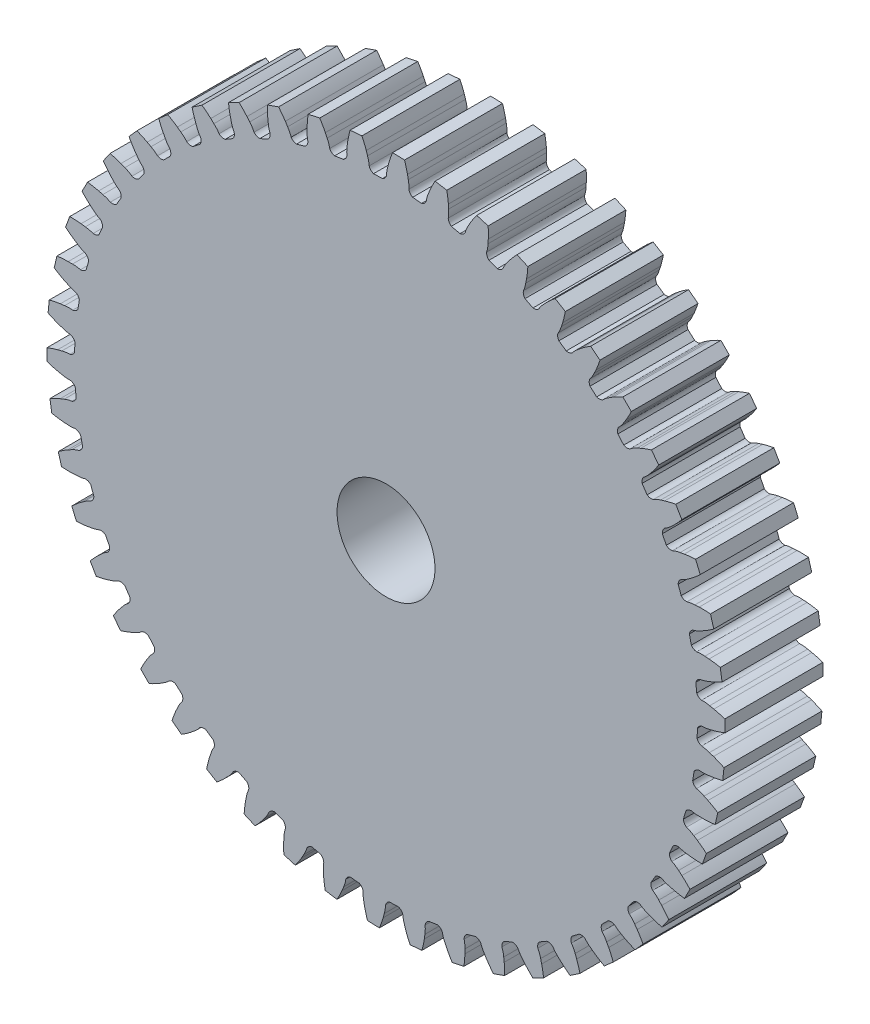
from build123d import *

# Parameters (mm, degrees)
SKETCH1_R           = 4.7625
BOSS_EXTRUDE1_DEPTH = 9.525


with BuildPart() as part:
    # Sketch1 → Boss-Extrude1 (new body)
    with BuildSketch(Plane.XY.offset(1.5875)):
        with BuildLine():
            Line((6.085438436, 30.919392842), (6.062246116, 31.336269955))
            ThreePointArc((6.062246116, 31.336269955), (6.001052011, 31.883634451), (5.910596918, 32.426930398))
            Line((5.910596918, 32.426930398), (4.768209334, 32.614492662))
            ThreePointArc((4.768209334, 32.614492662), (4.508784057, 32.128641722), (4.275782706, 31.62957962))
            Line((4.275782706, 31.62957962), (4.120511883, 31.242003688))
            ThreePointArc((4.120511883, 31.242003688), (3.986075895, 30.873495612), (3.905799746, 30.489533403))
            ThreePointArc((3.905799746, 30.489533403), (3.727534066, 30.231876604), (3.451724443, 30.083233639))
            Line((3.451724443, 30.083233639), (2.587721108, 30.169836618))
            ThreePointArc((2.587721108, 30.169836618), (2.346900416, 30.370263844), (2.223319664, 30.658176117))
            ThreePointArc((2.223319664, 30.658176117), (2.220847526, 31.050432572), (2.162225747, 31.438291727))
            Line((2.162225747, 31.438291727), (2.086968012, 31.848975337))
            ThreePointArc((2.086968012, 31.848975337), (1.95765348, 32.384354046), (1.799818614, 32.912028913))
            Line((1.799818614, 32.912028913), (0.642931656, 32.954932589))
            ThreePointArc((0.642931656, 32.954932589), (0.446445294, 32.44039812), (0.277830295, 31.91606846))
            Line((0.277830295, 31.91606846), (0.172358481, 31.512087724))
            ThreePointArc((0.172358481, 31.512087724), (0.08516887, 31.129636146), (0.053648947, 30.738640325))
            ThreePointArc((0.053648947, 30.738640325), (-0.090918094, 30.460672611), (-0.345922972, 30.278633629))
            Line((-0.345922972, 30.278633629), (-1.213966616, 30.256265696))
            ThreePointArc((-1.213966616, 30.256265696), (-1.478008558, 30.424929657), (-1.636699814, 30.695082881))
            ThreePointArc((-1.636699814, 30.695082881), (-1.688315229, 31.083936434), (-1.795086399, 31.461389947))
            Line((-1.795086399, 31.461389947), (-1.921223502, 31.859402127))
            ThreePointArc((-1.921223502, 31.859402127), (-2.116619096, 32.374351806), (-2.339344585, 32.878083845))
            Line((-2.339344585, 32.878083845), (-3.492487041, 32.775654376))
            ThreePointArc((-3.492487041, 32.775654376), (-3.62293578, 32.240550893), (-3.724505268, 31.699222666))
            Line((-3.724505268, 31.699222666), (-3.778512742, 31.285208424))
            ThreePointArc((-3.778512742, 31.285208424), (-3.817080944, 30.894844835), (-3.799347552, 30.502981639))
            ThreePointArc((-3.799347552, 30.502981639), (-3.907936047, 30.209086729), (-4.138114602, 29.996522592))
            Line((-4.138114602, 29.996522592), (-4.996509748, 29.865535709))
            ThreePointArc((-4.996509748, 29.865535709), (-5.27960884, 29.999776475), (-5.470907945, 30.247910171))
            ThreePointArc((-5.470907945, 30.247910171), (-5.57085263, 30.627228372), (-5.724089348, 30.988323575))
            Line((-5.724089348, 30.988323575), (-5.89911614, 31.367388156))
            ThreePointArc((-5.89911614, 31.367388156), (-6.157511289, 31.853787742), (-6.441614886, 32.325632798))
            Line((-6.441614886, 32.325632798), (-7.57282653, 32.07948314))
            ThreePointArc((-7.57282653, 32.07948314), (-7.635180392, 31.532249546), (-7.668102557, 30.982459821))
            Line((-7.668102557, 30.982459821), (-7.669793667, 30.564942038))
            ThreePointArc((-7.669793667, 30.564942038), (-7.659132216, 30.172822706), (-7.592425175, 29.786272052))
            ThreePointArc((-7.592425175, 29.786272052), (-7.663322618, 29.481084845), (-7.865044795, 29.241347818))
            Line((-7.865044795, 29.241347818), (-8.700255525, 29.003808645))
            ThreePointArc((-8.700255525, 29.003808645), (-8.997947125, 29.101509159), (-9.218837178, 29.323710111))
            ThreePointArc((-9.218837178, 29.323710111), (-9.365534946, 29.687510883), (-9.562820575, 30.026553089))
            Line((-9.562820575, 30.026553089), (-9.783976429, 30.380691916))
            ThreePointArc((-9.783976429, 30.380691916), (-10.101296088, 30.830870596), (-10.44229731, 31.26338739))
            Line((-10.44229731, 31.26338739), (-11.533737667, 30.877400197))
            ThreePointArc((-11.533737667, 30.877400197), (-11.527013311, 30.326666697), (-11.490768998, 29.777085989))
            Line((-11.490768998, 29.777085989), (-11.440118251, 29.362647673))
            ThreePointArc((-11.440118251, 29.362647673), (-11.380395286, 28.974956553), (-11.265766607, 28.599814575))
            ThreePointArc((-11.265766607, 28.599814575), (-11.297854903, 28.288148054), (-11.467939424, 28.025018932))
            Line((-11.467939424, 28.025018932), (-12.266792404, 27.684673899))
            ThreePointArc((-12.266792404, 27.684673899), (-12.574381738, 27.744293364), (-12.821379171, 27.937057331))
            ThreePointArc((-12.821379171, 27.937057331), (-13.012516511, 28.27960332), (-13.25073974, 28.591245632))
            Line((-13.25073974, 28.591245632), (-13.514537215, 28.914874117))
            ThreePointArc((-13.514537215, 28.914874117), (-13.885777064, 29.321732305), (-14.278298117, 29.708099788))
            Line((-14.278298117, 29.708099788), (-15.312755079, 29.188361936))
            ThreePointArc((-15.312755079, 29.188361936), (-15.23705852, 28.642813917), (-15.132219229, 28.102109438))
            Line((-15.132219229, 28.102109438), (-15.030024806, 27.697287318))
            ThreePointArc((-15.030024806, 27.697287318), (-14.922182192, 27.32013853), (-14.761439638, 26.962321442))
            ThreePointArc((-14.761439638, 26.962321442), (-14.754212735, 26.649090775), (-14.889977265, 26.366719262))
            Line((-14.889977265, 26.366719262), (-15.639875071, 25.928934516))
            ThreePointArc((-15.639875071, 25.928934516), (-15.952511272, 25.949532697), (-16.221720788, 26.109819677))
            ThreePointArc((-16.221720788, 26.109819677), (-16.454283349, 26.425708727), (-16.729687256, 26.705036359))
            Line((-16.729687256, 26.705036359), (-17.031965222, 26.993050323))
            ThreePointArc((-17.031965222, 26.993050323), (-17.451270586, 27.350171622), (-17.88912118, 27.684296549))
            Line((-17.88912118, 27.684296549), (-18.850280985, 27.039006064))
            ThreePointArc((-18.850280985, 27.039006064), (-18.706806018, 26.507247149), (-18.535025176, 25.983946133))
            Line((-18.535025176, 25.983946133), (-18.382899573, 25.59512483))
            ThreePointArc((-18.382899573, 25.59512483), (-18.228638052, 25.234466237), (-18.024316629, 24.899617027))
            ThreePointArc((-18.024316629, 24.899617027), (-17.977888499, 24.589762048), (-18.07719195, 24.292601311))
            Line((-18.07719195, 24.292601311), (-18.766306679, 23.764281408))
            ThreePointArc((-18.766306679, 23.764281408), (-19.079059286, 23.745533461), (-19.36623529, 23.87081563))
            ThreePointArc((-19.36623529, 23.87081563), (-19.636555422, 24.155065983), (-19.944796722, 24.39767377))
            Line((-19.944796722, 24.39767377), (-20.280789146, 24.645531267))
            ThreePointArc((-20.280789146, 24.645531267), (-20.741547329, 24.947283661), (-21.217822298, 25.223896683))
            Line((-21.217822298, 25.223896683), (-22.090527723, 24.463229262))
            ThreePointArc((-22.090527723, 24.463229262), (-21.881537035, 23.953645606), (-21.645523728, 23.456000825))
            Line((-21.645523728, 23.456000825), (-21.445865244, 23.089311554))
            ThreePointArc((-21.445865244, 23.089311554), (-21.247617614, 22.750830957), (-21.002939592, 22.444230398))
            ThreePointArc((-21.002939592, 22.444230398), (-20.918042436, 22.142637706), (-20.979318734, 21.835374148))
            Line((-20.979318734, 21.835374148), (-21.596782974, 21.224851026))
            ThreePointArc((-21.596782974, 21.224851026), (-21.904719693, 21.167052617), (-22.205333247, 21.255354202))
            ThreePointArc((-22.205333247, 21.255354202), (-22.509147841, 21.50348306), (-22.845365384, 21.705544934))
            Line((-22.845365384, 21.705544934), (-23.209773217, 21.90933683))
            ThreePointArc((-23.209773217, 21.90933683), (-23.704717787, 22.150961503), (-24.21190599, 22.365700267))
            Line((-24.21190599, 22.365700267), (-24.982392281, 21.501652308))
            ThreePointArc((-24.982392281, 21.501652308), (-24.711181779, 21.022280351), (-24.414658078, 20.558139957))
            Line((-24.414658078, 20.558139957), (-24.170615976, 20.2193654))
            ThreePointArc((-24.170615976, 20.2193654), (-23.931508721, 19.908400839), (-23.650332818, 19.634884205))
            ThreePointArc((-23.650332818, 19.634884205), (-23.528305514, 19.346310096), (-23.550588294, 19.033789446))
            Line((-23.550588294, 19.033789446), (-24.086664767, 18.350692018))
            ThreePointArc((-24.086664767, 18.350692018), (-24.384929251, 18.254754661), (-24.694239501, 18.304683093))
            ThreePointArc((-24.694239501, 18.304683093), (-25.026757217, 18.512777315), (-25.385648653, 18.671106638))
            Line((-25.385648653, 18.671106638), (-25.772725689, 18.827619065))
            ThreePointArc((-25.772725689, 18.827619065), (-26.294051076, 19.005305452), (-26.824153852, 19.154783399))
            Line((-26.824153852, 19.154783399), (-27.480270644, 18.200980636))
            ThreePointArc((-27.480270644, 18.200980636), (-27.151117481, 17.759380359), (-26.798759741, 17.336064126))
            Line((-26.798759741, 17.336064126), (-26.51418142, 17.030548191))
            ThreePointArc((-26.51418142, 17.030548191), (-26.237985403, 16.752003765), (-25.924745932, 16.515884576))
            ThreePointArc((-25.924745932, 16.515884576), (-25.767512924, 16.244880038), (-25.750450774, 15.932030933))
            Line((-25.750450774, 15.932030933), (-26.196686033, 15.1871315))
            ThreePointArc((-26.196686033, 15.1871315), (-26.480574474, 15.054568186), (-26.793703412, 15.065336063))
            ThreePointArc((-26.793703412, 15.065336063), (-27.149680248, 15.23011388), (-27.525585643, 15.342213705))
            Line((-27.525585643, 15.342213705), (-27.929226296, 15.448979136))
            ThreePointArc((-27.929226296, 15.448979136), (-28.468710885, 15.559925016), (-29.013368197, 15.64178479))
            Line((-29.013368197, 15.64178479), (-29.544768503, 14.613269187))
            ThreePointArc((-29.544768503, 14.613269187), (-29.16286362, 14.21640489), (-28.760228734, 13.840588766))
            Line((-28.760228734, 13.840588766), (-28.439603329, 13.573149218))
            ThreePointArc((-28.439603329, 13.573149218), (-28.130674327, 13.331417738), (-27.790311262, 13.136419735))
            ThreePointArc((-27.790311262, 13.136419735), (-27.600352208, 12.88725867), (-27.544214208, 12.579014929))
            Line((-27.544214208, 12.579014929), (-27.893569751, 11.784061661))
            ThreePointArc((-27.893569751, 11.784061661), (-28.158605058, 11.616962992), (-28.470614454, 11.588400499))
            ThreePointArc((-28.470614454, 11.588400499), (-28.844436444, 11.707263265), (-29.231427546, 11.771365712))
            Line((-29.231427546, 11.771365712), (-29.645266329, 11.826698552))
            ThreePointArc((-29.645266329, 11.826698552), (-30.194402127, 11.869154242), (-30.745024403, 11.882104865))
            Line((-30.745024403, 11.882104865), (-31.143327378, 10.795098128))
            ThreePointArc((-31.143327378, 10.795098128), (-30.714693643, 10.449228599), (-30.268131403, 10.126839429))
            Line((-30.268131403, 10.126839429), (-29.916515236, 9.901693916))
            ThreePointArc((-29.916515236, 9.901693916), (-29.579725242, 9.700587631), (-29.21760631, 9.54978605))
            ThreePointArc((-29.21760631, 9.54978605), (-28.997916978, 9.326397876), (-28.903588459, 9.027620686))
            Line((-28.903588459, 9.027620686), (-29.150555456, 8.195149524))
            ThreePointArc((-29.150555456, 8.195149524), (-29.392557863, 7.996150745), (-29.698527141, 7.928708328))
            ThreePointArc((-29.698527141, 7.928708328), (-30.084298888, 7.999781508), (-30.476272617, 8.014875641))
            Line((-30.476272617, 8.014875641), (-30.893782738, 8.017904628))
            ThreePointArc((-30.893782738, 8.017904628), (-31.443909545, 7.991200577), (-31.991813144, 7.935037811))
            Line((-31.991813144, 7.935037811), (-32.25073682, 6.806681784))
            ThreePointArc((-32.25073682, 6.806681784), (-31.782134044, 6.517261591), (-31.298687004, 6.253383646))
            Line((-31.298687004, 6.253383646), (-30.921625717, 6.074081718))
            ThreePointArc((-30.921625717, 6.074081718), (-30.562286113, 5.916772196), (-30.184122148, 5.812545266))
            ThreePointArc((-30.184122148, 5.812545266), (-29.938167169, 5.618452949), (-29.807135746, 5.333854205))
            Line((-29.807135746, 5.333854205), (-29.947819312, 4.476994858))
            ThreePointArc((-29.947819312, 4.476994858), (-30.162972298, 4.2492343), (-30.458076142, 4.143975568))
            ThreePointArc((-30.458076142, 4.143975568), (-30.849713795, 4.166138294), (-31.240488491, 4.13198607))
            Line((-31.240488491, 4.13198607), (-31.655086395, 4.082663752))
            ThreePointArc((-31.655086395, 4.082663752), (-32.197528383, 3.987221099), (-32.734072537, 3.862830663))
            Line((-32.734072537, 3.862830663), (-32.849533851, 2.710919691))
            ThreePointArc((-32.849533851, 2.710919691), (-32.348352179, 2.482513164), (-31.835644587, 2.281307956))
            Line((-31.835644587, 2.281307956), (-31.439083789, 2.150679158))
            ThreePointArc((-31.439083789, 2.150679158), (-31.062861573, 2.039647262), (-30.674616446, 1.983638706))
            ThreePointArc((-30.674616446, 1.983638706), (-30.406274678, 1.821903197), (-30.240606797, 1.555971191))
            Line((-30.240606797, 1.555971191), (-30.272787429, 0.68823538))
            ThreePointArc((-30.272787429, 0.68823538), (-30.457697902, 0.435304962), (-30.737282347, 0.293889908))
            ThreePointArc((-30.737282347, 0.293889908), (-31.128609546, 0.266792661), (-31.512022458, 0.183932681))
            Line((-31.512022458, 0.183932681), (-31.917169539, 0.083035566))
            ThreePointArc((-31.917169539, 0.083035566), (-32.443372074, -0.079640502), (-32.960095162, -0.270296896))
            Line((-32.960095162, -0.270296896), (-32.930274282, -1.42759468))
            ThreePointArc((-32.930274282, -1.42759468), (-32.404417649, -1.591385434), (-31.87053521, -1.726744778))
            Line((-31.87053521, -1.726744778), (-31.460728941, -1.80664165))
            ThreePointArc((-31.460728941, -1.80664165), (-31.073557364, -1.869644879), (-30.681353933, -1.876551774))
            ThreePointArc((-30.681353933, -1.876551774), (-30.394857286, -2.003379808), (-30.197165627, -2.24645117))
            Line((-30.197165627, -2.24645117), (-30.120336016, -3.11137848))
            ThreePointArc((-30.120336016, -3.11137848), (-30.272087828, -3.385489893), (-30.531743659, -3.560831069))
            ThreePointArc((-30.531743659, -3.560831069), (-30.916588941, -3.63676095), (-31.286593419, -3.767021934))
            Line((-31.286593419, -3.767021934), (-31.675900348, -3.9179011))
            ThreePointArc((-31.675900348, -3.9179011), (-32.1775649, -4.145245083), (-32.66631789, -4.399160671))
            Line((-32.66631789, -4.399160671), (-32.491683956, -5.543595523))
            ThreePointArc((-32.491683956, -5.543595523), (-31.949445434, -5.640187426), (-31.402807794, -5.707566209))
            Line((-31.402807794, -5.707566209), (-30.986219394, -5.735470936))
            ThreePointArc((-30.986219394, -5.735470936), (-30.594204378, -5.7494519), (-30.204227921, -5.707148207))
            ThreePointArc((-30.204227921, -5.707148207), (-29.904094651, -5.797068631), (-29.677497001, -6.013446004))
            Line((-29.677497001, -6.013446004), (-29.492869909, -6.861922732))
            ThreePointArc((-29.492869909, -6.861922732), (-29.609069842, -7.15289224), (-29.844702133, -7.359394304))
            ThreePointArc((-29.844702133, -7.359394304), (-30.216996256, -7.482959358), (-30.567757107, -7.658567052))
            Line((-30.567757107, -7.658567052), (-30.935083595, -7.857050144))
            ThreePointArc((-30.935083595, -7.857050144), (-31.404298616, -8.145476692), (-31.857373581, -8.458647072))
            Line((-31.857373581, -8.458647072), (-31.540680308, -9.57217011))
            ThreePointArc((-31.540680308, -9.57217011), (-30.990611324, -9.60003985), (-30.439839284, -9.598375468))
            Line((-30.439839284, -9.598375468), (-30.023038138, -9.573848376))
            ThreePointArc((-30.023038138, -9.573848376), (-29.632362002, -9.538586587), (-29.250762687, -9.447739461))
            ThreePointArc((-29.250762687, -9.447739461), (-28.941726009, -9.499334141), (-28.689795808, -9.685605052))
            Line((-28.689795808, -9.685605052), (-28.40028195, -10.504251243))
            ThreePointArc((-28.40028195, -10.504251243), (-28.479097464, -10.807490083), (-28.686990153, -11.041896373))
            ThreePointArc((-28.686990153, -11.041896373), (-29.040861818, -11.211147906), (-29.366847334, -11.429332874))
            Line((-29.366847334, -11.429332874), (-29.706401449, -11.672288879))
            ThreePointArc((-29.706401449, -11.672288879), (-30.135767138, -12.017249334), (-30.546018815, -12.384735621))
            Line((-30.546018815, -12.384735621), (-30.092261924, -13.449786068))
            ThreePointArc((-30.092261924, -13.449786068), (-29.543037394, -13.408494122), (-28.996816959, -13.337812823))
            Line((-28.996816959, -13.337812823), (-28.586376398, -13.261240036))
            ThreePointArc((-28.586376398, -13.261240036), (-28.203200333, -13.177291593), (-27.835996206, -13.039333748))
            ThreePointArc((-27.835996206, -13.039333748), (-27.522929847, -13.051789022), (-27.249640254, -13.205015905))
            Line((-27.249640254, -13.205015905), (-26.859805671, -13.980921564))
            ThreePointArc((-26.859805671, -13.980921564), (-26.899993796, -14.291647478), (-27.07686829, -14.550261268))
            ThreePointArc((-27.07686829, -14.550261268), (-27.406736731, -14.762530083), (-27.702805928, -15.019851416))
            Line((-27.702805928, -15.019851416), (-28.00923164, -15.303448859))
            ThreePointArc((-28.00923164, -15.303448859), (-28.391976643, -15.699502988), (-28.752935118, -16.115509706))
            Line((-28.752935118, -16.115509706), (-28.169269978, -17.115291233))
            ThreePointArc((-28.169269978, -17.115291233), (-27.6295515, -17.0054888), (-27.096496891, -16.866905271))
            Line((-27.096496891, -16.866905271), (-26.698890177, -16.739493865))
            ThreePointArc((-26.698890177, -16.739493865), (-26.329257101, -16.608182685), (-25.982239192, -16.425289799))
            ThreePointArc((-25.982239192, -16.425289799), (-25.670080395, -16.39840924), (-25.379741352, -16.516175615))
            Line((-25.379741352, -16.516175615), (-24.89573371, -17.237104081))
            ThreePointArc((-24.89573371, -17.237104081), (-24.896660657, -17.550416736), (-25.03972754, -17.829159531))
            ThreePointArc((-25.03972754, -17.829159531), (-25.340390532, -18.081098021), (-25.601874221, -18.373497609))
            Line((-25.601874221, -18.373497609), (-25.870340459, -18.693264551))
            ThreePointArc((-25.870340459, -18.693264551), (-26.200428659, -19.134166343), (-26.506401401, -19.592132817))
            Line((-26.506401401, -19.592132817), (-25.802031546, -20.510878331))
            ThreePointArc((-25.802031546, -20.510878331), (-25.280330803, -20.334297061), (-24.768848611, -20.129996847))
            Line((-24.768848611, -20.129996847), (-24.3903466, -19.953756287))
            ThreePointArc((-24.3903466, -19.953756287), (-24.040085845, -19.777153227), (-23.718726831, -19.552209629))
            ThreePointArc((-23.718726831, -19.552209629), (-23.412398527, -19.48641716), (-23.109588853, -19.566865781))
            Line((-23.109588853, -19.566865781), (-22.539042496, -20.221447404))
            ThreePointArc((-22.539042496, -20.221447404), (-22.500693645, -20.532405672), (-22.607696667, -20.826881532))
            ThreePointArc((-22.607696667, -20.826881532), (-22.874412576, -21.114516477), (-23.097187001, -21.437383002))
            Line((-23.097187001, -21.437383002), (-23.323457383, -21.788276077))
            ThreePointArc((-23.323457383, -21.788276077), (-23.595683092, -22.267072248), (-23.841844728, -22.759776073))
            Line((-23.841844728, -22.759776073), (-23.027880867, -23.582995438))
            ThreePointArc((-23.027880867, -23.582995438), (-22.532425392, -23.342420123), (-22.050581996, -23.07562516))
            Line((-22.050581996, -23.07562516), (-21.697152753, -22.853336525))
            ThreePointArc((-21.697152753, -22.853336525), (-21.371788142, -22.63422672), (-21.08115605, -22.370779906))
            ThreePointArc((-21.08115605, -22.370779906), (-20.785489219, -22.267113114), (-20.474984405, -22.308975257))
            Line((-20.474984405, -22.308975257), (-19.826895336, -22.886886495))
            ThreePointArc((-19.826895336, -22.886886495), (-19.749875472, -23.19058638), (-19.819127133, -23.496151244))
            ThreePointArc((-19.819127133, -23.496151244), (-20.047689689, -23.814946469), (-20.228241565, -24.163188133))
            Line((-20.228241565, -24.163188133), (-20.408750501, -24.53967271))
            ThreePointArc((-20.408750501, -24.53967271), (-20.618820555, -25.048812359), (-20.801288971, -25.5684833))
            Line((-20.801288971, -25.5684833), (-19.89056557, -26.283195764))
            ThreePointArc((-19.89056557, -26.283195764), (-19.429168992, -25.98242042), (-18.98456335, -25.657338224))
            Line((-18.98456335, -25.657338224), (-18.661781956, -25.392505186))
            ThreePointArc((-18.661781956, -25.392505186), (-18.366444682, -25.134344127), (-18.111122951, -24.836548809))
            ThreePointArc((-18.111122951, -24.836548809), (-17.830780436, -24.69664258), (-17.517477326, -24.699258055))
            Line((-17.517477326, -24.699258055), (-16.802066556, -25.191385053))
            ThreePointArc((-16.802066556, -25.191385053), (-16.687590328, -25.483037025), (-16.717998486, -25.794871954))
            ThreePointArc((-16.717998486, -25.794871954), (-16.904803122, -26.139799867), (-17.040285039, -26.507924692))
            Line((-17.040285039, -26.507924692), (-17.172184356, -26.904065367))
            ThreePointArc((-17.172184356, -26.904065367), (-17.316785827, -27.435519057), (-17.432683385, -27.973961594))
            Line((-17.432683385, -27.973961594), (-16.439564788, -28.568892965))
            ThreePointArc((-16.439564788, -28.568892965), (-16.019503605, -28.212661), (-15.619147415, -27.834418311))
            Line((-15.619147415, -27.834418311), (-15.332103182, -27.531218623))
            ThreePointArc((-15.332103182, -27.531218623), (-15.071450891, -27.238077666), (-14.855466099, -26.910630255))
            ThreePointArc((-14.855466099, -26.910630255), (-14.594869067, -26.736690995), (-14.28370864, -26.700018556))
            Line((-14.28370864, -26.700018556), (-13.512259585, -27.098601105))
            ThreePointArc((-13.512259585, -27.098601105), (-13.362132351, -27.373605637), (-13.353217452, -27.686792807))
            ThreePointArc((-13.353217452, -27.686792807), (-13.495318146, -28.05241369), (-13.583593473, -28.434616128))
            Line((-13.583593473, -28.434616128), (-13.664803323, -28.844163938))
            ThreePointArc((-13.664803323, -28.844163938), (-13.741655759, -29.389550327), (-13.789154686, -29.938272899))
            Line((-13.789154686, -29.938272899), (-12.729301879, -30.404042756))
            ThreePointArc((-12.729301879, -30.404042756), (-12.357200709, -29.99797216), (-12.007407826, -29.572534092))
            Line((-12.007407826, -29.572534092), (-11.7606287, -29.235749664))
            ThreePointArc((-11.7606287, -29.235749664), (-11.538772034, -28.912251817), (-11.365530389, -28.560316354))
            ThreePointArc((-11.365530389, -28.560316354), (-11.128788613, -28.355087187), (-10.824678055, -28.279705178))
            Line((-10.824678055, -28.279705178), (-10.009356524, -28.578456088))
            ThreePointArc((-10.009356524, -28.578456088), (-9.825945881, -28.832476196), (-9.777848518, -29.142076459))
            ThreePointArc((-9.777848518, -29.142076459), (-9.873004259, -29.522624251), (-9.912680841, -29.91287674))
            Line((-9.912680841, -29.91287674), (-9.941920181, -30.329372968))
            ThreePointArc((-9.941920181, -30.329372968), (-9.949811573, -30.880090987), (-9.928162782, -31.430439912))
            Line((-9.928162782, -31.430439912), (-8.818291242, -31.759702212))
            ThreePointArc((-8.818291242, -31.759702212), (-8.500018341, -31.310196961), (-8.206305209, -30.844272926))
            Line((-8.206305209, -30.844272926), (-8.003680824, -30.479214118))
            ThreePointArc((-8.003680824, -30.479214118), (-7.824118595, -30.130461136), (-7.696352222, -29.759587854))
            ThreePointArc((-7.696352222, -29.759587854), (-7.487199262, -29.526305369), (-7.194934578, -29.41340261))
            Line((-7.194934578, -29.41340261), (-6.348599059, -29.607611173))
            ThreePointArc((-6.348599059, -29.607611173), (-6.134797502, -29.836640808), (-6.048276199, -30.137771582))
            ThreePointArc((-6.048276199, -30.137771582), (-6.094986323, -30.527244818), (-6.085438437, -30.919392845))
            Line((-6.085438437, -30.919392845), (-6.062246117, -31.336269957))
            ThreePointArc((-6.062246117, -31.336269957), (-6.001052012, -31.883634453), (-5.910596919, -32.4269304))
            Line((-5.910596919, -32.4269304), (-4.768209335, -32.614492664))
            ThreePointArc((-4.768209335, -32.614492664), (-4.508784058, -32.128641724), (-4.275782707, -31.629579623))
            Line((-4.275782707, -31.629579623), (-4.120511884, -31.242003691))
            ThreePointArc((-4.120511884, -31.242003691), (-3.986075896, -30.873495614), (-3.905799747, -30.489533406))
            ThreePointArc((-3.905799747, -30.489533406), (-3.727534067, -30.231876606), (-3.451724445, -30.083233641))
            Line((-3.451724445, -30.083233641), (-2.587721109, -30.16983662))
            ThreePointArc((-2.587721109, -30.16983662), (-2.346900417, -30.370263847), (-2.223319666, -30.65817612))
            ThreePointArc((-2.223319666, -30.65817612), (-2.220847527, -31.050432574), (-2.162225749, -31.43829173))
            Line((-2.162225749, -31.43829173), (-2.086968013, -31.848975339))
            ThreePointArc((-2.086968013, -31.848975339), (-1.957653481, -32.384354048), (-1.799818615, -32.912028915))
            Line((-1.799818615, -32.912028915), (-0.642931657, -32.954932591))
            ThreePointArc((-0.642931657, -32.954932591), (-0.446445295, -32.440398122), (-0.277830296, -31.916068462))
            Line((-0.277830296, -31.916068462), (-0.172358482, -31.512087726))
            ThreePointArc((-0.172358482, -31.512087726), (-0.085168871, -31.129636149), (-0.053648948, -30.738640328))
            ThreePointArc((-0.053648948, -30.738640328), (0.090918093, -30.460672614), (0.345922971, -30.278633631))
            Line((0.345922971, -30.278633631), (1.213966615, -30.256265698))
            ThreePointArc((1.213966615, -30.256265698), (1.478008557, -30.42492966), (1.636699813, -30.695082884))
            ThreePointArc((1.636699813, -30.695082884), (1.688315228, -31.083936437), (1.795086398, -31.46138995))
            Line((1.795086398, -31.46138995), (1.921223501, -31.85940213))
            ThreePointArc((1.921223501, -31.85940213), (2.116619094, -32.374351809), (2.339344583, -32.878083847))
            Line((2.339344583, -32.878083847), (3.492487039, -32.775654378))
            ThreePointArc((3.492487039, -32.775654378), (3.622935779, -32.240550896), (3.724505266, -31.699222669))
            Line((3.724505266, -31.699222669), (3.778512741, -31.285208426))
            ThreePointArc((3.778512741, -31.285208426), (3.817080943, -30.894844837), (3.799347551, -30.502981641))
            ThreePointArc((3.799347551, -30.502981641), (3.907936046, -30.209086731), (4.138114601, -29.996522594))
            Line((4.138114601, -29.996522594), (4.996509747, -29.865535711))
            ThreePointArc((4.996509747, -29.865535711), (5.279608839, -29.999776477), (5.470907943, -30.247910174))
            ThreePointArc((5.470907943, -30.247910174), (5.570852629, -30.627228374), (5.724089346, -30.988323578))
            Line((5.724089346, -30.988323578), (5.899116138, -31.367388159))
            ThreePointArc((5.899116138, -31.367388159), (6.157511288, -31.853787745), (6.441614885, -32.3256328))
            Line((6.441614885, -32.3256328), (7.572826529, -32.079483142))
            ThreePointArc((7.572826529, -32.079483142), (7.635180391, -31.532249549), (7.668102555, -30.982459824))
            Line((7.668102555, -30.982459824), (7.669793666, -30.56494204))
            ThreePointArc((7.669793666, -30.56494204), (7.659132215, -30.172822708), (7.592425174, -29.786272054))
            ThreePointArc((7.592425174, -29.786272054), (7.663322617, -29.481084847), (7.865044794, -29.24134782))
            Line((7.865044794, -29.24134782), (8.700255524, -29.003808648))
            ThreePointArc((8.700255524, -29.003808648), (8.997947124, -29.101509161), (9.218837177, -29.323710114))
            ThreePointArc((9.218837177, -29.323710114), (9.365534945, -29.687510886), (9.562820574, -30.026553091))
            Line((9.562820574, -30.026553091), (9.783976428, -30.380691919))
            ThreePointArc((9.783976428, -30.380691919), (10.101296087, -30.830870599), (10.442297309, -31.263387392))
            Line((10.442297309, -31.263387392), (11.533737666, -30.877400199))
            ThreePointArc((11.533737666, -30.877400199), (11.52701331, -30.3266667), (11.490768997, -29.777085992))
            Line((11.490768997, -29.777085992), (11.44011825, -29.362647675))
            ThreePointArc((11.44011825, -29.362647675), (11.380395284, -28.974956555), (11.265766606, -28.599814578))
            ThreePointArc((11.265766606, -28.599814578), (11.297854902, -28.288148057), (11.467939423, -28.025018934))
            Line((11.467939423, -28.025018934), (12.266792403, -27.684673901))
            ThreePointArc((12.266792403, -27.684673901), (12.574381737, -27.744293366), (12.82137917, -27.937057334))
            ThreePointArc((12.82137917, -27.937057334), (13.01251651, -28.279603323), (13.250739739, -28.591245634))
            Line((13.250739739, -28.591245634), (13.514537214, -28.91487412))
            ThreePointArc((13.514537214, -28.91487412), (13.885777063, -29.321732307), (14.278298116, -29.708099791))
            Line((14.278298116, -29.708099791), (15.312755078, -29.188361939))
            ThreePointArc((15.312755078, -29.188361939), (15.237058519, -28.642813919), (15.132219228, -28.102109441))
            Line((15.132219228, -28.102109441), (15.030024805, -27.69728732))
            ThreePointArc((15.030024805, -27.69728732), (14.922182191, -27.320138533), (14.761439637, -26.962321445))
            ThreePointArc((14.761439637, -26.962321445), (14.754212734, -26.649090778), (14.889977264, -26.366719264))
            Line((14.889977264, -26.366719264), (15.63987507, -25.928934519))
            ThreePointArc((15.63987507, -25.928934519), (15.952511271, -25.9495327), (16.221720787, -26.109819679))
            ThreePointArc((16.221720787, -26.109819679), (16.454283348, -26.42570873), (16.729687255, -26.705036361))
            Line((16.729687255, -26.705036361), (17.031965221, -26.993050326))
            ThreePointArc((17.031965221, -26.993050326), (17.451270585, -27.350171624), (17.889121179, -27.684296552))
            Line((17.889121179, -27.684296552), (18.850280984, -27.039006067))
            ThreePointArc((18.850280984, -27.039006067), (18.706806016, -26.507247151), (18.535025174, -25.983946136))
            Line((18.535025174, -25.983946136), (18.382899571, -25.595124833))
            ThreePointArc((18.382899571, -25.595124833), (18.228638051, -25.234466239), (18.024316627, -24.89961703))
            ThreePointArc((18.024316627, -24.89961703), (17.977888498, -24.589762051), (18.077191949, -24.292601314))
            Line((18.077191949, -24.292601314), (18.766306677, -23.764281411))
            ThreePointArc((18.766306677, -23.764281411), (19.079059285, -23.745533463), (19.366235288, -23.870815633))
            ThreePointArc((19.366235288, -23.870815633), (19.636555421, -24.155065986), (19.944796721, -24.397673773))
            Line((19.944796721, -24.397673773), (20.280789145, -24.64553127))
            ThreePointArc((20.280789145, -24.64553127), (20.741547328, -24.947283663), (21.217822297, -25.223896686))
            Line((21.217822297, -25.223896686), (22.090527722, -24.463229265))
            ThreePointArc((22.090527722, -24.463229265), (21.881537034, -23.953645609), (21.645523727, -23.456000827))
            Line((21.645523727, -23.456000827), (21.445865243, -23.089311557))
            ThreePointArc((21.445865243, -23.089311557), (21.247617613, -22.750830959), (21.002939591, -22.444230401))
            ThreePointArc((21.002939591, -22.444230401), (20.918042435, -22.142637709), (20.979318733, -21.835374151))
            Line((20.979318733, -21.835374151), (21.596782973, -21.224851028))
            ThreePointArc((21.596782973, -21.224851028), (21.904719692, -21.167052619), (22.205333246, -21.255354204))
            ThreePointArc((22.205333246, -21.255354204), (22.50914784, -21.503483062), (22.845365383, -21.705544936))
            Line((22.845365383, -21.705544936), (23.209773216, -21.909336833))
            ThreePointArc((23.209773216, -21.909336833), (23.704717786, -22.150961506), (24.211905989, -22.36570027))
            Line((24.211905989, -22.36570027), (24.98239228, -21.501652311))
            ThreePointArc((24.98239228, -21.501652311), (24.711181778, -21.022280353), (24.414658077, -20.55813996))
            Line((24.414658077, -20.55813996), (24.170615975, -20.219365402))
            ThreePointArc((24.170615975, -20.219365402), (23.93150872, -19.908400842), (23.650332817, -19.634884208))
            ThreePointArc((23.650332817, -19.634884208), (23.528305513, -19.346310099), (23.550588293, -19.033789449))
            Line((23.550588293, -19.033789449), (24.086664766, -18.350692021))
            ThreePointArc((24.086664766, -18.350692021), (24.38492925, -18.254754664), (24.6942395, -18.304683095))
            ThreePointArc((24.6942395, -18.304683095), (25.026757216, -18.512777317), (25.385648652, -18.67110664))
            Line((25.385648652, -18.67110664), (25.772725688, -18.827619068))
            ThreePointArc((25.772725688, -18.827619068), (26.294051075, -19.005305454), (26.824153851, -19.154783402))
            Line((26.824153851, -19.154783402), (27.480270643, -18.200980639))
            ThreePointArc((27.480270643, -18.200980639), (27.151117479, -17.759380362), (26.79875974, -17.336064128))
            Line((26.79875974, -17.336064128), (26.514181419, -17.030548194))
            ThreePointArc((26.514181419, -17.030548194), (26.237985402, -16.752003767), (25.924745931, -16.515884579))
            ThreePointArc((25.924745931, -16.515884579), (25.767512923, -16.24488004), (25.750450773, -15.932030936))
            Line((25.750450773, -15.932030936), (26.196686032, -15.187131503))
            ThreePointArc((26.196686032, -15.187131503), (26.480574473, -15.054568189), (26.793703411, -15.065336066))
            ThreePointArc((26.793703411, -15.065336066), (27.149680247, -15.230113883), (27.525585642, -15.342213708))
            Line((27.525585642, -15.342213708), (27.929226295, -15.448979139))
            ThreePointArc((27.929226295, -15.448979139), (28.468710884, -15.559925019), (29.013368196, -15.641784793))
            Line((29.013368196, -15.641784793), (29.544768502, -14.61326919))
            ThreePointArc((29.544768502, -14.61326919), (29.162863619, -14.216404893), (28.760228733, -13.840588769))
            Line((28.760228733, -13.840588769), (28.439603328, -13.57314922))
            ThreePointArc((28.439603328, -13.57314922), (28.130674326, -13.33141774), (27.790311261, -13.136419738))
            ThreePointArc((27.790311261, -13.136419738), (27.600352207, -12.887258672), (27.544214207, -12.579014931))
            Line((27.544214207, -12.579014931), (27.89356975, -11.784061664))
            ThreePointArc((27.89356975, -11.784061664), (28.158605057, -11.616962994), (28.470614453, -11.588400501))
            ThreePointArc((28.470614453, -11.588400501), (28.844436443, -11.707263268), (29.231427545, -11.771365714))
            Line((29.231427545, -11.771365714), (29.645266328, -11.826698554))
            ThreePointArc((29.645266328, -11.826698554), (30.194402126, -11.869154244), (30.745024402, -11.882104868))
            Line((30.745024402, -11.882104868), (31.143327377, -10.795098131))
            ThreePointArc((31.143327377, -10.795098131), (30.714693642, -10.449228601), (30.268131402, -10.126839432))
            Line((30.268131402, -10.126839432), (29.916515235, -9.901693919))
            ThreePointArc((29.916515235, -9.901693919), (29.579725241, -9.700587634), (29.217606309, -9.549786053))
            ThreePointArc((29.217606309, -9.549786053), (28.997916977, -9.326397879), (28.903588458, -9.027620689))
            Line((28.903588458, -9.027620689), (29.150555455, -8.195149526))
            ThreePointArc((29.150555455, -8.195149526), (29.392557862, -7.996150747), (29.69852714, -7.928708331))
            ThreePointArc((29.69852714, -7.928708331), (30.084298886, -7.999781511), (30.476272615, -8.014875644))
            Line((30.476272615, -8.014875644), (30.893782736, -8.017904631))
            ThreePointArc((30.893782736, -8.017904631), (31.443909544, -7.99120058), (31.991813143, -7.935037814))
            Line((31.991813143, -7.935037814), (32.250736819, -6.806681787))
            ThreePointArc((32.250736819, -6.806681787), (31.782134043, -6.517261593), (31.298687003, -6.253383649))
            Line((31.298687003, -6.253383649), (30.921625716, -6.074081721))
            ThreePointArc((30.921625716, -6.074081721), (30.562286112, -5.916772198), (30.184122147, -5.812545269))
            ThreePointArc((30.184122147, -5.812545269), (29.938167168, -5.618452952), (29.807135745, -5.333854208))
            Line((29.807135745, -5.333854208), (29.947819311, -4.476994861))
            ThreePointArc((29.947819311, -4.476994861), (30.162972297, -4.249234303), (30.458076141, -4.143975571))
            ThreePointArc((30.458076141, -4.143975571), (30.849713794, -4.166138297), (31.24048849, -4.131986073))
            Line((31.24048849, -4.131986073), (31.655086394, -4.082663755))
            ThreePointArc((31.655086394, -4.082663755), (32.197528382, -3.987221102), (32.734072536, -3.862830666))
            Line((32.734072536, -3.862830666), (32.84953385, -2.710919694))
            ThreePointArc((32.84953385, -2.710919694), (32.348352178, -2.482513166), (31.835644586, -2.281307959))
            Line((31.835644586, -2.281307959), (31.439083788, -2.150679161))
            ThreePointArc((31.439083788, -2.150679161), (31.062861572, -2.039647265), (30.674616445, -1.983638709))
            ThreePointArc((30.674616445, -1.983638709), (30.406274677, -1.8219032), (30.240606796, -1.555971193))
            Line((30.240606796, -1.555971193), (30.272787428, -0.688235383))
            ThreePointArc((30.272787428, -0.688235383), (30.457697901, -0.435304965), (30.737282346, -0.293889911))
            ThreePointArc((30.737282346, -0.293889911), (31.128609545, -0.266792663), (31.512022457, -0.183932683))
            Line((31.512022457, -0.183932683), (31.917169538, -0.083035568))
            ThreePointArc((31.917169538, -0.083035568), (32.443372073, 0.079640499), (32.960095161, 0.270296893))
            Line((32.960095161, 0.270296893), (32.930274281, 1.427594677))
            ThreePointArc((32.930274281, 1.427594677), (32.404417647, 1.591385431), (31.870535209, 1.726744775))
            Line((31.870535209, 1.726744775), (31.46072894, 1.806641648))
            ThreePointArc((31.46072894, 1.806641648), (31.073557363, 1.869644876), (30.681353932, 1.876551772))
            ThreePointArc((30.681353932, 1.876551772), (30.394857285, 2.003379806), (30.197165626, 2.246451168))
            Line((30.197165626, 2.246451168), (30.120336015, 3.111378478))
            ThreePointArc((30.120336015, 3.111378478), (30.272087826, 3.38548989), (30.531743658, 3.560831067))
            ThreePointArc((30.531743658, 3.560831067), (30.91658894, 3.636760947), (31.286593417, 3.767021932))
            Line((31.286593417, 3.767021932), (31.675900347, 3.917901097))
            ThreePointArc((31.675900347, 3.917901097), (32.177564899, 4.145245081), (32.666317889, 4.399160668))
            Line((32.666317889, 4.399160668), (32.491683955, 5.54359552))
            ThreePointArc((32.491683955, 5.54359552), (31.949445433, 5.640187423), (31.402807793, 5.707566206))
            Line((31.402807793, 5.707566206), (30.986219393, 5.735470933))
            ThreePointArc((30.986219393, 5.735470933), (30.594204377, 5.749451898), (30.20422792, 5.707148204))
            ThreePointArc((30.20422792, 5.707148204), (29.90409465, 5.797068629), (29.677497, 6.013446001))
            Line((29.677497, 6.013446001), (29.492869908, 6.861922729))
            ThreePointArc((29.492869908, 6.861922729), (29.609069841, 7.152892237), (29.844702132, 7.359394301))
            ThreePointArc((29.844702132, 7.359394301), (30.216996255, 7.482959355), (30.567757106, 7.65856705))
            Line((30.567757106, 7.65856705), (30.935083594, 7.857050141))
            ThreePointArc((30.935083594, 7.857050141), (31.404298615, 8.14547669), (31.85737358, 8.458647069))
            Line((31.85737358, 8.458647069), (31.540680307, 9.572170107))
            ThreePointArc((31.540680307, 9.572170107), (30.990611323, 9.600039847), (30.439839283, 9.598375465))
            Line((30.439839283, 9.598375465), (30.023038137, 9.573848373))
            ThreePointArc((30.023038137, 9.573848373), (29.632362001, 9.538586584), (29.250762686, 9.447739458))
            ThreePointArc((29.250762686, 9.447739458), (28.941726008, 9.499334138), (28.689795807, 9.68560505))
            Line((28.689795807, 9.68560505), (28.400281949, 10.504251241))
            ThreePointArc((28.400281949, 10.504251241), (28.479097462, 10.80749008), (28.686990151, 11.041896371))
            ThreePointArc((28.686990151, 11.041896371), (29.040861817, 11.211147904), (29.366847333, 11.429332871))
            Line((29.366847333, 11.429332871), (29.706401448, 11.672288876))
            ThreePointArc((29.706401448, 11.672288876), (30.135767137, 12.017249331), (30.546018814, 12.384735618))
            Line((30.546018814, 12.384735618), (30.092261923, 13.449786066))
            ThreePointArc((30.092261923, 13.449786066), (29.543037393, 13.408494119), (28.996816957, 13.337812821))
            Line((28.996816957, 13.337812821), (28.586376397, 13.261240034))
            ThreePointArc((28.586376397, 13.261240034), (28.203200332, 13.17729159), (27.835996205, 13.039333745))
            ThreePointArc((27.835996205, 13.039333745), (27.522929846, 13.05178902), (27.249640253, 13.205015903))
            Line((27.249640253, 13.205015903), (26.85980567, 13.980921561))
            ThreePointArc((26.85980567, 13.980921561), (26.899993795, 14.291647476), (27.076868289, 14.550261266))
            ThreePointArc((27.076868289, 14.550261266), (27.40673673, 14.76253008), (27.702805927, 15.019851413))
            Line((27.702805927, 15.019851413), (28.009231639, 15.303448857))
            ThreePointArc((28.009231639, 15.303448857), (28.391976642, 15.699502985), (28.752935117, 16.115509704))
            Line((28.752935117, 16.115509704), (28.169269977, 17.115291231))
            ThreePointArc((28.169269977, 17.115291231), (27.629551499, 17.005488797), (27.09649689, 16.866905269))
            Line((27.09649689, 16.866905269), (26.698890176, 16.739493862))
            ThreePointArc((26.698890176, 16.739493862), (26.3292571, 16.608182683), (25.982239191, 16.425289797))
            ThreePointArc((25.982239191, 16.425289797), (25.670080394, 16.398409237), (25.379741351, 16.516175612))
            Line((25.379741351, 16.516175612), (24.895733709, 17.237104078))
            ThreePointArc((24.895733709, 17.237104078), (24.896660655, 17.550416733), (25.039727539, 17.829159529))
            ThreePointArc((25.039727539, 17.829159529), (25.340390531, 18.081098019), (25.60187422, 18.373497606))
            Line((25.60187422, 18.373497606), (25.870340458, 18.693264549))
            ThreePointArc((25.870340458, 18.693264549), (26.200428658, 19.134166341), (26.5064014, 19.592132815))
            Line((26.5064014, 19.592132815), (25.802031545, 20.510878329))
            ThreePointArc((25.802031545, 20.510878329), (25.280330802, 20.334297058), (24.76884861, 20.129996844))
            Line((24.76884861, 20.129996844), (24.390346599, 19.953756285))
            ThreePointArc((24.390346599, 19.953756285), (24.040085844, 19.777153225), (23.71872683, 19.552209627))
            ThreePointArc((23.71872683, 19.552209627), (23.412398526, 19.486417158), (23.109588852, 19.566865778))
            Line((23.109588852, 19.566865778), (22.539041445, 20.221447252))
            ThreePointArc((22.539041445, 20.221447252), (22.500692593, 20.53240552), (22.607695616, 20.82688138))
            ThreePointArc((22.607695616, 20.82688138), (22.874411525, 21.114516325), (23.097185951, 21.43738285))
            Line((23.097185951, 21.43738285), (23.323457382, 21.788276074))
            ThreePointArc((23.323457382, 21.788276074), (23.595683091, 22.267072246), (23.841844727, 22.75977607))
            Line((23.841844727, 22.75977607), (23.027880866, 23.582995435))
            ThreePointArc((23.027880866, 23.582995435), (22.532425391, 23.34242012), (22.050581995, 23.075625157))
            Line((22.050581995, 23.075625157), (21.697152752, 22.853336522))
            ThreePointArc((21.697152752, 22.853336522), (21.371788141, 22.634226717), (21.081156049, 22.370779903))
            ThreePointArc((21.081156049, 22.370779903), (20.785489218, 22.267113111), (20.474984404, 22.308975255))
            Line((20.474984404, 22.308975255), (19.826895335, 22.886886493))
            ThreePointArc((19.826895335, 22.886886493), (19.749875471, 23.190586377), (19.819127131, 23.496151242))
            ThreePointArc((19.819127131, 23.496151242), (20.047689688, 23.814946466), (20.228241564, 24.163188131))
            Line((20.228241564, 24.163188131), (20.4087505, 24.539672707))
            ThreePointArc((20.4087505, 24.539672707), (20.618820554, 25.048812356), (20.80128897, 25.568483298))
            Line((20.80128897, 25.568483298), (19.890565569, 26.283195762))
            ThreePointArc((19.890565569, 26.283195762), (19.429168991, 25.982420417), (18.984563349, 25.657338221))
            Line((18.984563349, 25.657338221), (18.661781955, 25.392505183))
            ThreePointArc((18.661781955, 25.392505183), (18.366444681, 25.134344125), (18.11112295, 24.836548807))
            ThreePointArc((18.11112295, 24.836548807), (17.830780435, 24.696642577), (17.517477325, 24.699258053))
            Line((17.517477325, 24.699258053), (16.802066555, 25.191385051))
            ThreePointArc((16.802066555, 25.191385051), (16.687590327, 25.483037022), (16.717998485, 25.794871951))
            ThreePointArc((16.717998485, 25.794871951), (16.904803121, 26.139799864), (17.040285038, 26.50792469))
            Line((17.040285038, 26.50792469), (17.172184355, 26.904065365))
            ThreePointArc((17.172184355, 26.904065365), (17.316785826, 27.435519054), (17.432683384, 27.973961592))
            Line((17.432683384, 27.973961592), (16.439564787, 28.568892963))
            ThreePointArc((16.439564787, 28.568892963), (16.019503604, 28.212660997), (15.619147414, 27.834418309))
            Line((15.619147414, 27.834418309), (15.332103181, 27.531218621))
            ThreePointArc((15.332103181, 27.531218621), (15.07145089, 27.238077664), (14.855466097, 26.910630252))
            ThreePointArc((14.855466097, 26.910630252), (14.594869066, 26.736690992), (14.283708639, 26.700018553))
            Line((14.283708639, 26.700018553), (13.512259584, 27.098601103))
            ThreePointArc((13.512259584, 27.098601103), (13.36213235, 27.373605635), (13.353217451, 27.686792805))
            ThreePointArc((13.353217451, 27.686792805), (13.495318145, 28.052413687), (13.583593472, 28.434616125))
            Line((13.583593472, 28.434616125), (13.664803322, 28.844163935))
            ThreePointArc((13.664803322, 28.844163935), (13.741655758, 29.389550324), (13.789154685, 29.938272897))
            Line((13.789154685, 29.938272897), (12.729301878, 30.404042754))
            ThreePointArc((12.729301878, 30.404042754), (12.357200708, 29.997972157), (12.007407825, 29.57253409))
            Line((12.007407825, 29.57253409), (11.760628699, 29.235749661))
            ThreePointArc((11.760628699, 29.235749661), (11.538772033, 28.912251814), (11.365530388, 28.560316351))
            ThreePointArc((11.365530388, 28.560316351), (11.128788612, 28.355087185), (10.824678054, 28.279705176))
            Line((10.824678054, 28.279705176), (10.009356523, 28.578456086))
            ThreePointArc((10.009356523, 28.578456086), (9.82594588, 28.832476194), (9.777848517, 29.142076456))
            ThreePointArc((9.777848517, 29.142076456), (9.873004258, 29.522624248), (9.91268084, 29.912876738))
            Line((9.91268084, 29.912876738), (9.94192018, 30.329372966))
            ThreePointArc((9.94192018, 30.329372966), (9.949811571, 30.880090984), (9.928162781, 31.43043991))
            Line((9.928162781, 31.43043991), (8.818291241, 31.75970221))
            ThreePointArc((8.818291241, 31.75970221), (8.50001834, 31.310196958), (8.206305208, 30.844272924))
            Line((8.206305208, 30.844272924), (8.003680823, 30.479214116))
            ThreePointArc((8.003680823, 30.479214116), (7.824118594, 30.130461133), (7.696352221, 29.759587852))
            ThreePointArc((7.696352221, 29.759587852), (7.487199261, 29.526305366), (7.194934577, 29.413402608))
            Line((7.194934577, 29.413402608), (6.348599058, 29.607611171))
            ThreePointArc((6.348599058, 29.607611171), (6.134797501, 29.836640805), (6.048276198, 30.137771579))
            ThreePointArc((6.048276198, 30.137771579), (6.094986322, 30.527244815), (6.085438436, 30.919392842))
        make_face()
        with Locations(Location((0, 0, 0), (0, 0, 180))):  # turned: the seam where the file's is
            Circle(SKETCH1_R, mode=Mode.SUBTRACT)
    extrude(amount=-BOSS_EXTRUDE1_DEPTH)


solid = part.part
